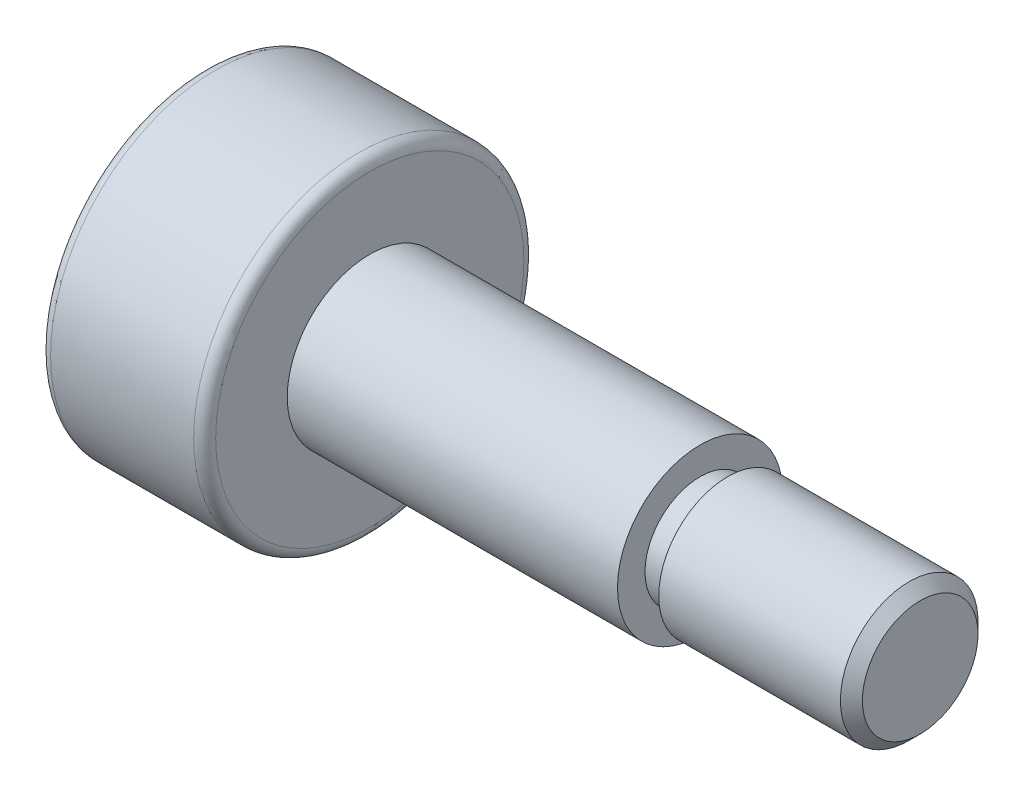
from build123d import *

# Parameters (mm, degrees)
FILLET_1_R          = 0.2
CHAMFER_1_SIZE      = 0.2
SKETCH_3_W          = 0.5
SKETCH_3_H          = 0.25
CUT_EXTRUDE_1_DEPTH = 2


with BuildPart() as part:
    # 草图1 → 旋转1 (revolve)
    with BuildSketch(Plane.XY):
        Polygon((-6.5, 0), (-6.5, 3), (-3.5, 3), (-3.5, 1.5), (2.5, 1.5), (2.5, 1.25), (6.5, 1.25), (6.5, 0), align=None)
    revolve(axis=Axis((-6.5, 0, 0), (1, 0, 0)))

    # 圆角1
    fillet_1_edges = [part.edges().sort_by_distance(p)[0] for p in [
        (-3.5, -3, 0),
        (-6.5, -3, 0),
    ]]
    fillet(fillet_1_edges, radius=FILLET_1_R)

    # 倒角1
    chamfer_1_edges = [part.edges().sort_by_distance(p)[0] for p in [
        (6.5, -1.25, 0),
    ]]
    chamfer(chamfer_1_edges, length=CHAMFER_1_SIZE)

    # 草图3 → 切除-旋转1 (revolve, cut)
    with BuildSketch(Plane.XY):
        with Locations((2.75, 1.125)):
            Rectangle(SKETCH_3_W, SKETCH_3_H)
    revolve(axis=Axis((2.5, 0, 0), (1, 0, 0)), mode=Mode.SUBTRACT)

    # 草图4 → 切除-拉伸1 (cut)
    with BuildSketch(Plane.ZY.offset(6.5)):
        Polygon((1.732050808, 0), (0.866025404, 1.5), (-0.866025404, 1.5), (-1.732050808, 0), (-0.866025404, -1.5), (0.866025404, -1.5), align=None)
    extrude(amount=-CUT_EXTRUDE_1_DEPTH, mode=Mode.SUBTRACT)


solid = part.part
